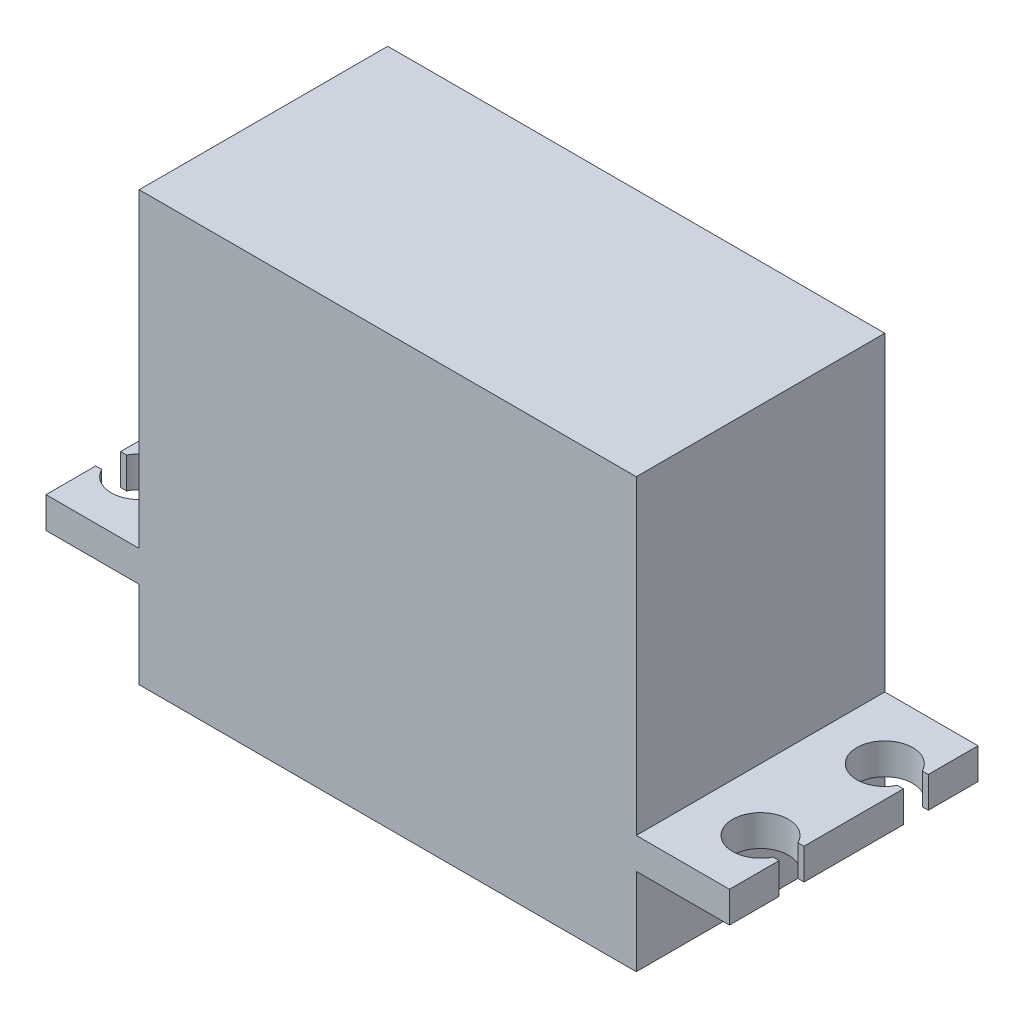
from build123d import *

# Parameters (mm, degrees)
SKETCH1_W                = 40
SKETCH1_H                = 20
BOSS_EXTRUDE1_DEPTH      = 25
BOSS_EXTRUDE1_DEPTH_BACK = 9.5
BOSS_EXTRUDE2_DEPTH      = 2.5
SKETCH3_R                = 3
BOSS_EXTRUDE3_DEPTH      = 6


with BuildPart() as part:
    # Sketch1 → Boss-Extrude1 (new body, two sides)
    with BuildSketch(Plane(origin=(0, 0, 0), x_dir=(1, 0, 0), z_dir=(0, 1, 0))) as boss_extrude1_sk:
        with Locations((-20, 0)):
            Rectangle(SKETCH1_W, SKETCH1_H)
    extrude(amount=BOSS_EXTRUDE1_DEPTH)
    extrude(boss_extrude1_sk.sketch, amount=-BOSS_EXTRUDE1_DEPTH_BACK)

    # Sketch2 → Boss-Extrude2 (add)
    with BuildSketch(Plane(origin=(0, 0, 0), x_dir=(1, 0, 0), z_dir=(0, 1, 0))):
        with BuildLine():
            Line((-40, 10), (-47.5, 10))
            Line((-47.5, 10), (-47.5, 6))
            Line((-47.5, 6), (-47.015564437, 6))
            ThreePointArc((-47.015564437, 6), (-42.75, 5), (-47.015564437, 4))
            Line((-47.015564437, 4), (-47.5, 4))
            Line((-47.5, 4), (-47.5, -4))
            Line((-47.5, -4), (-47.015564437, -4))
            ThreePointArc((-47.015564437, -4), (-42.75, -5), (-47.015564437, -6))
            Line((-47.015564437, -6), (-47.5, -6))
            Line((-47.5, -6), (-47.5, -10))
            Line((-47.5, -10), (-40, -10))
            Line((-40, -10), (-40, 10))
        make_face()
        with BuildLine():
            Line((7.5, -4), (7.5, 4))
            Line((7.5, 4), (7.015564437, 4))
            ThreePointArc((7.015564437, 4), (2.75, 5), (7.015564437, 6))
            Line((7.015564437, 6), (7.5, 6))
            Line((7.5, 6), (7.5, 10))
            Line((7.5, 10), (0, 10))
            Line((0, 10), (0, -10))
            Line((0, -10), (7.5, -10))
            Line((7.5, -10), (7.5, -6))
            Line((7.5, -6), (7.015564437, -6))
            ThreePointArc((7.015564437, -6), (2.75, -5), (7.015564437, -4))
            Line((7.015564437, -4), (7.5, -4))
        make_face()
    extrude(amount=-BOSS_EXTRUDE2_DEPTH)

    # Sketch3 → Boss-Extrude3 (add)
    with BuildSketch(Plane(origin=(0, -9.5, 0), x_dir=(-1, 0, 0), z_dir=(0, -1, 0))):
        with Locations((28.5, 0)):
            Circle(SKETCH3_R)
    extrude(amount=BOSS_EXTRUDE3_DEPTH)


solid = part.part
